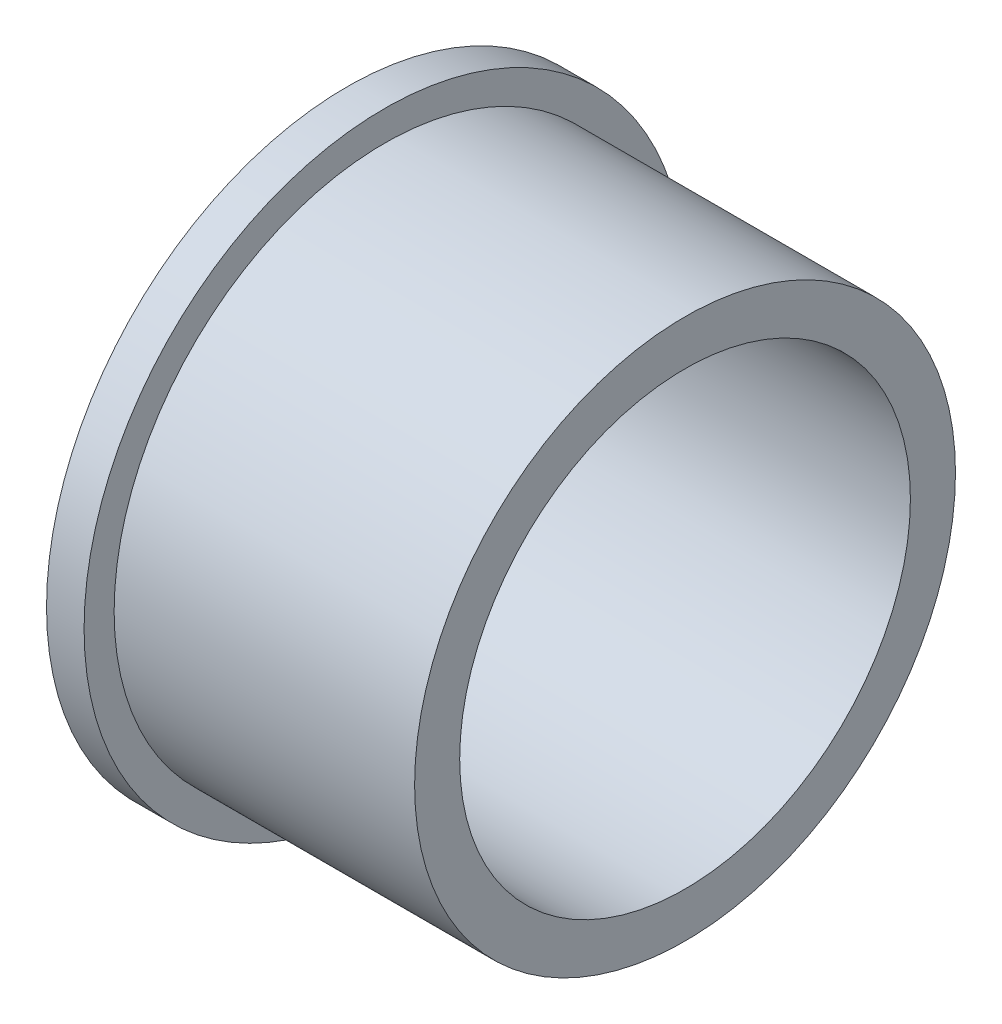
from build123d import *


with BuildPart() as part:
    # Sketch1 → Revolve1 (revolve)
    with BuildSketch(Plane.XY):
        Polygon((0, 20), (0, 15), (22.5, 15), (22.5, 18), (2.5, 18), (2.5, 20), align=None)
    revolve(axis=Axis((-84.410714624, 0, 0), (1, 0, 0)))


solid = part.part
